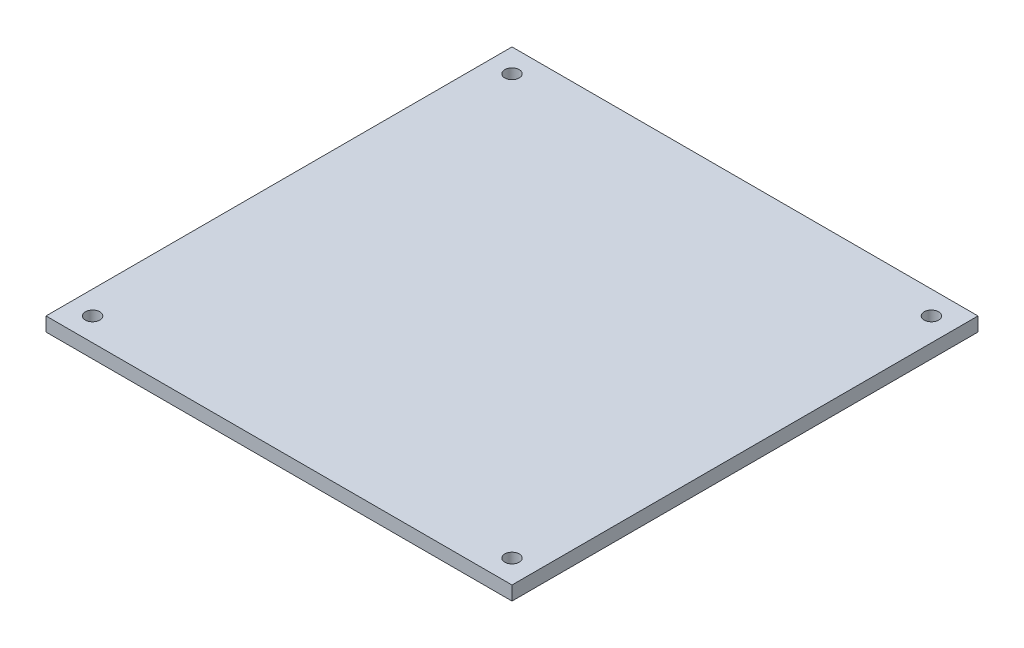
from build123d import *

# Parameters (mm, degrees)
SKETCH1_W           = 100
SKETCH1_H           = 100
SKETCH1_R           = 1.55
BOSS_EXTRUDE1_DEPTH = 3


with BuildPart() as part:
    # Sketch1 → Boss-Extrude1 (new body)
    with BuildSketch(Plane(origin=(0, 0, 0), x_dir=(1, 0, 0), z_dir=(0, 1, 0))):
        Rectangle(SKETCH1_W, SKETCH1_H)
        with Locations((-45, -45)):
            Circle(SKETCH1_R, mode=Mode.SUBTRACT)
        with Locations((45, -45)):
            Circle(SKETCH1_R, mode=Mode.SUBTRACT)
        with Locations((45, 45)):
            Circle(SKETCH1_R, mode=Mode.SUBTRACT)
        with Locations((-45, 45)):
            Circle(SKETCH1_R, mode=Mode.SUBTRACT)
    extrude(amount=BOSS_EXTRUDE1_DEPTH)


solid = part.part
